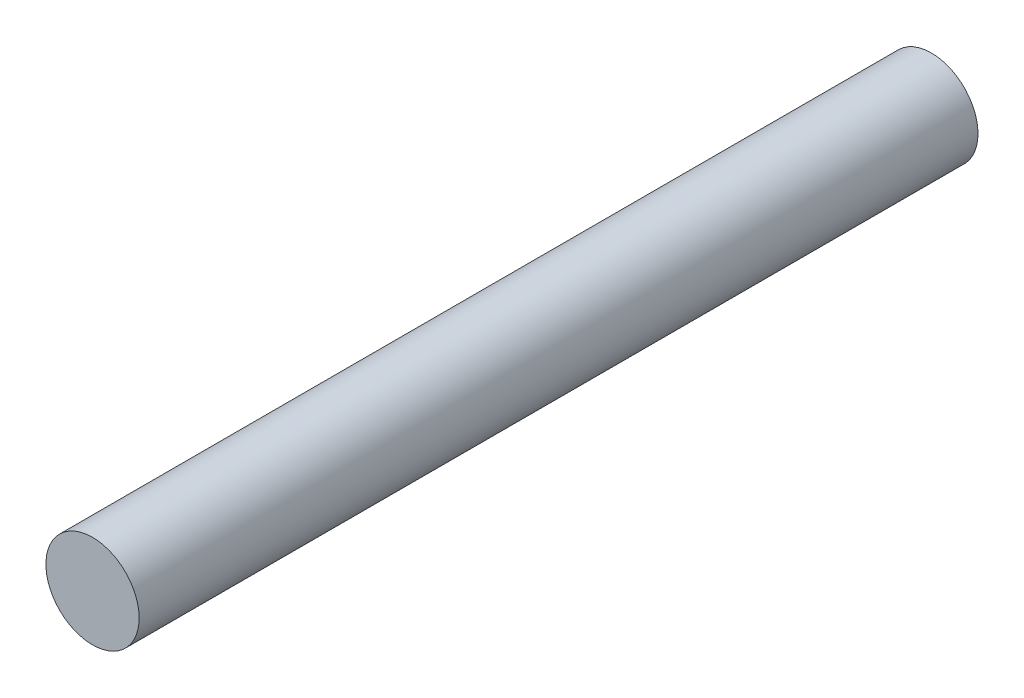
from build123d import *

# Parameters (mm, degrees)
SKETCH1_R           = 1
BOSS_EXTRUDE1_DEPTH = 18


with BuildPart() as part:
    # Sketch1 → Boss-Extrude1 (new body)
    with BuildSketch(Plane.XY):
        Circle(SKETCH1_R)
    extrude(amount=BOSS_EXTRUDE1_DEPTH)


solid = part.part
